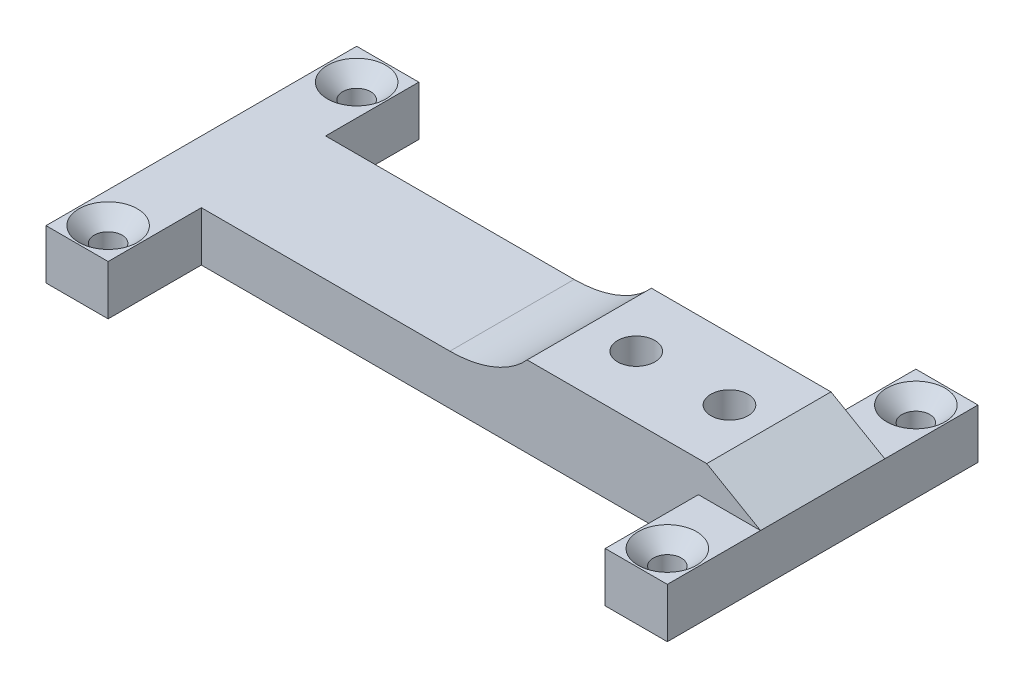
from build123d import *

# Parameters (mm, degrees)
SKETCH1_W                                       = 50
SKETCH1_H                                       = 8
BOSS_EXTRUDE1_DEPTH                             = 20
SKETCH2_R                                       = 3
CUT_EXTRUDE1_DEPTH                              = 17
CUT_EXTRUDE2_DEPTH                              = 4
SKETCH4_W                                       = 10
SKETCH4_H                                       = 15
BOSS_EXTRUDE2_DEPTH                             = 8
CSK_FOR_M4_FLAT_HEAD_MACHINE_SCREW1_D           = 4.5
CSK_FOR_M4_FLAT_HEAD_MACHINE_SCREW1_CSINK_D     = 9.4
CSK_FOR_M4_FLAT_HEAD_MACHINE_SCREW1_CSINK_ANGLE = 90


with BuildPart() as part:
    # Sketch1 → Boss-Extrude1 (new body)
    with BuildSketch(Plane.XY):
        with Locations((-25, -15.35)):
            Rectangle(SKETCH1_W, SKETCH1_H)
        with Locations((25, -15.35)):
            Rectangle(SKETCH1_W, SKETCH1_H)
        with BuildLine():
            Line((40, -6.35), (12.432745191, -6.35))
            add(Edge.make_bspline(
                [(0, -11.35), (7.972410052, -11.35), (12.432745191, -6.35)],
                knots=[1.570796327, 1.570796327, 1.570796327, 2.547844784, 2.547844784, 2.547844784], degree=2, weights=[1, 0.883026434, 1]))
            Line((0, -11.35), (50, -11.35))
            Line((50, -11.35), (41.339745962, -6.35))
            Line((41.339745962, -6.35), (40, -6.35))
        make_face()
    extrude(amount=BOSS_EXTRUDE1_DEPTH)

    # Sketch2 → Cut-Extrude1 (cut)
    with BuildSketch(Plane(origin=(0, -6.35, 0), x_dir=(1, 0, 0), z_dir=(0, 1, 0))):
        with Locations((35, -10)):
            Circle(SKETCH2_R)
        with Locations((20, -10)):
            Circle(SKETCH2_R)
    extrude(amount=-CUT_EXTRUDE1_DEPTH, mode=Mode.SUBTRACT)

    # Sketch3 → Cut-Extrude2 (cut)
    with BuildSketch(Plane.XZ.offset(19.35)):
        with BuildLine():
            Line((20, 15.5), (35, 15.5))
            ThreePointArc((35, 15.5), (40.5, 10), (35, 4.5))
            Line((35, 4.5), (20, 4.5))
            ThreePointArc((20, 4.5), (14.5, 10), (20, 15.5))
        make_face()
    extrude(amount=-CUT_EXTRUDE2_DEPTH, mode=Mode.SUBTRACT)

    # Sketch4 → Boss-Extrude2 (add)
    with BuildSketch(Plane.XZ.offset(19.35)):
        with Locations((-45, 27.5)):
            Rectangle(SKETCH4_W, SKETCH4_H)
        with Locations((45, 27.5)):
            Rectangle(SKETCH4_W, SKETCH4_H)
        with Locations((-45, -7.5)):
            Rectangle(SKETCH4_W, SKETCH4_H)
        with Locations((45, -7.5)):
            Rectangle(SKETCH4_W, SKETCH4_H)
    extrude(amount=-BOSS_EXTRUDE2_DEPTH)

    # CSK for M4 Flat Head Machine Screw1 (through all)
    with Locations(Plane(origin=(0, -11.35, 0), x_dir=(1, 0, 0), z_dir=(0, 1, 0))):
        with Locations((-45, 10), (-45, -30), (45, -30), (45, 10)):
            CounterSinkHole(CSK_FOR_M4_FLAT_HEAD_MACHINE_SCREW1_D / 2, CSK_FOR_M4_FLAT_HEAD_MACHINE_SCREW1_CSINK_D / 2, counter_sink_angle=CSK_FOR_M4_FLAT_HEAD_MACHINE_SCREW1_CSINK_ANGLE)


solid = part.part
